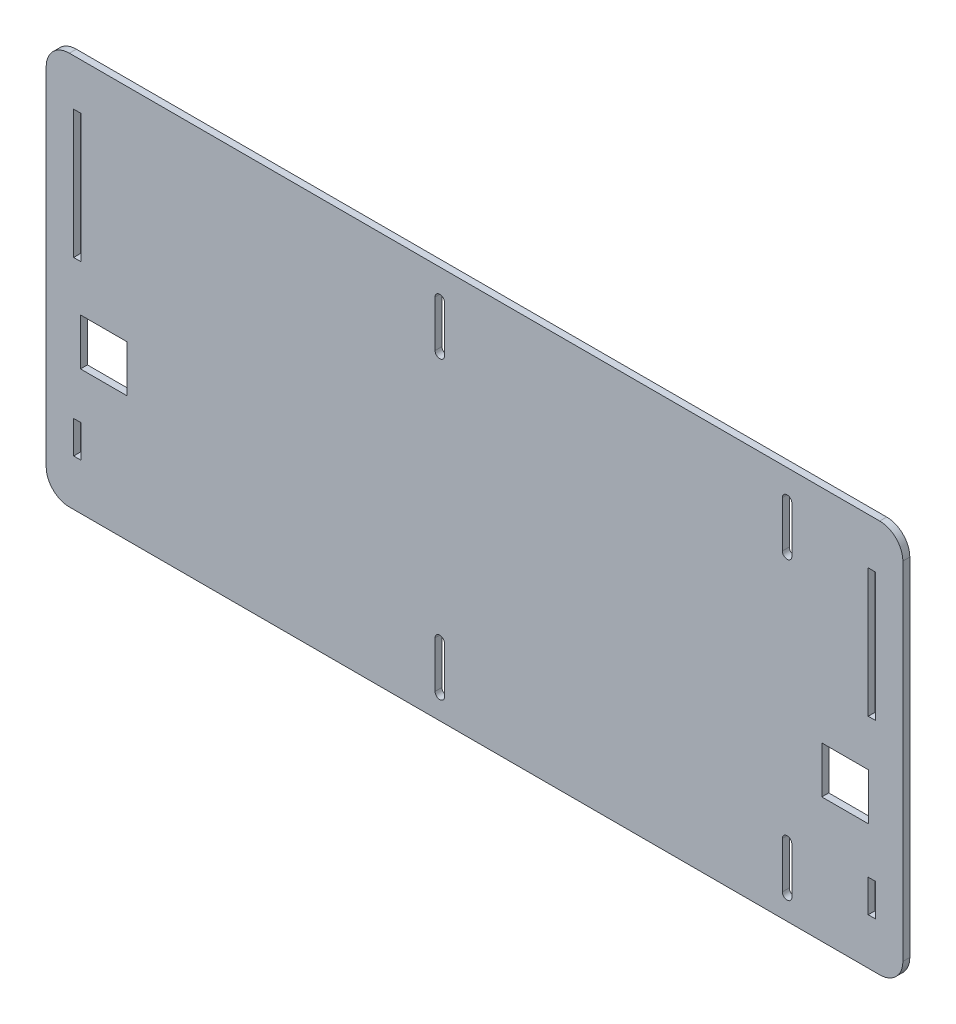
from build123d import *

# Parameters (mm, degrees)
SKETCH1_W           = 370
SKETCH1_H           = 169.75
BOSS_EXTRUDE1_DEPTH = 3
SKETCH3_W           = 20.2
SKETCH3_H           = 20.2
CUT_EXTRUDE1_DEPTH  = 4
SKETCH4_W           = 3.1
SKETCH4_H           = 55.5
SKETCH4_H_2         = 14.05
CUT_EXTRUDE2_DEPTH  = 4
FILLET1_R           = 10


with BuildPart() as part:
    # Sketch1 → Boss-Extrude1 (new body)
    with BuildSketch(Plane.XY):
        with Locations((440, -20.125)):
            Rectangle(SKETCH1_W, SKETCH1_H)
        with BuildLine():
            Line((427.05, 52.5), (427.05, 32.5))
            ThreePointArc((427.05, 32.5), (425, 30.45), (422.95, 32.5))
            Line((422.95, 32.5), (422.95, 52.5))
            ThreePointArc((422.95, 52.5), (425, 54.55), (427.05, 52.5))
        make_face(mode=Mode.SUBTRACT)
        with BuildLine():
            Line((572.95, 52.5), (572.95, 32.5))
            ThreePointArc((572.95, 32.5), (575, 30.45), (577.05, 32.5))
            Line((577.05, 32.5), (577.05, 52.5))
            ThreePointArc((577.05, 52.5), (575, 54.55), (572.95, 52.5))
        make_face(mode=Mode.SUBTRACT)
        with BuildLine():
            Line((427.05, -75), (427.05, -95))
            ThreePointArc((427.05, -95), (425, -97.05), (422.95, -95))
            Line((422.95, -95), (422.95, -75))
            ThreePointArc((422.95, -75), (425, -72.95), (427.05, -75))
        make_face(mode=Mode.SUBTRACT)
        with BuildLine():
            Line((572.95, -75), (572.95, -95))
            ThreePointArc((572.95, -95), (575, -97.05), (577.05, -95))
            Line((577.05, -95), (577.05, -75))
            ThreePointArc((577.05, -75), (575, -72.95), (572.95, -75))
        make_face(mode=Mode.SUBTRACT)
    extrude(amount=BOSS_EXTRUDE1_DEPTH)

    # Sketch3 → Cut-Extrude1 (cut, through all)
    with BuildSketch(Plane.XY.offset(3)):
        with Locations((279.9, -40.85)):
            Rectangle(SKETCH3_W, SKETCH3_H)
        with Locations((600.1, -40.85)):
            Rectangle(SKETCH3_W, SKETCH3_H)
    extrude(amount=-CUT_EXTRUDE1_DEPTH, mode=Mode.SUBTRACT)

    # Sketch4 → Cut-Extrude2 (cut, through all)
    with BuildSketch(Plane.XY.offset(3)):
        with Locations((268.4, 17)):
            Rectangle(SKETCH4_W, SKETCH4_H)
        with Locations((268.4, -77.975)):
            Rectangle(SKETCH4_W, SKETCH4_H_2)
        with Locations((611.6, -77.975)):
            Rectangle(SKETCH4_W, SKETCH4_H_2)
        with Locations((611.6, 17)):
            Rectangle(SKETCH4_W, SKETCH4_H)
    extrude(amount=-CUT_EXTRUDE2_DEPTH, mode=Mode.SUBTRACT)

    # Fillet1
    fillet1_edges = [part.edges().sort_by_distance(p)[0] for p in [
        (625, -105, 1.5),
        (255, -105, 1.5),
        (255, 64.75, 1.5),
        (625, 64.75, 1.5),
    ]]
    fillet(fillet1_edges, radius=FILLET1_R)


solid = part.part
